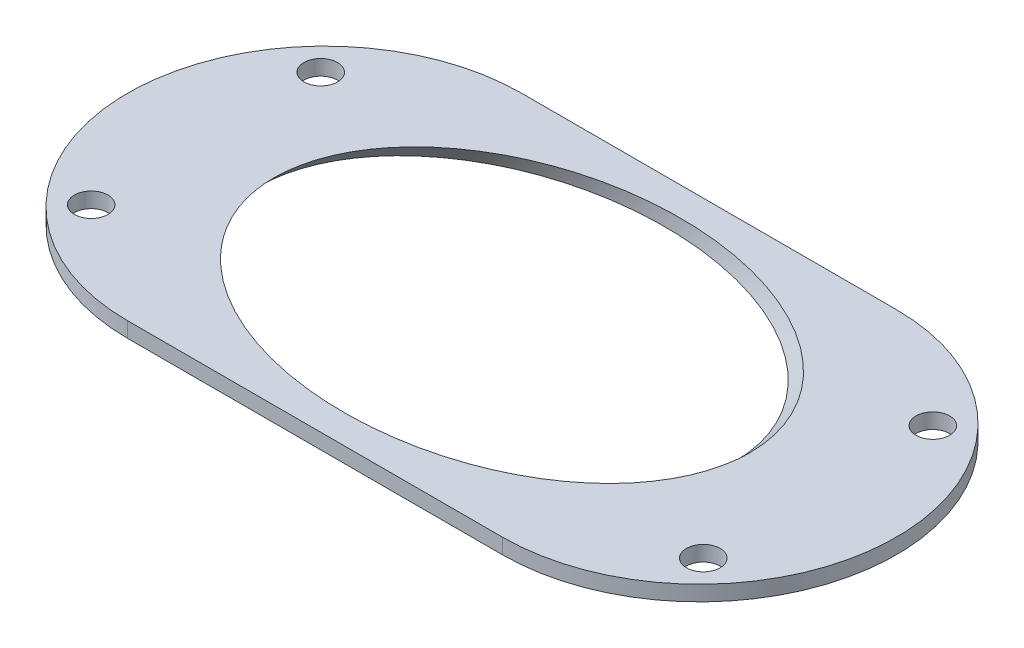
from build123d import *

# Parameters (mm, degrees)
BOSS_EXTRUDE1_DEPTH      = 1
SKETCH2_R                = 11
CUT_EXTRUDE1_DEPTH       = 10.811106589
CUT_EXTRUDE1_DEPTH_BACK  = 27.428115947
M2_CLEARANCE_HOLE1_D     = 2.2
M2_CLEARANCE_HOLE1_DEPTH = 1


with BuildPart() as part:
    # Sketch1 → Boss-Extrude1 (new body)
    with BuildSketch(Plane(origin=(0, 0, 0), x_dir=(1, 0, 0), z_dir=(0, 1, 0))):
        with BuildLine():
            Line((-12.25, 12.875), (12.25, 12.875))
            ThreePointArc((12.25, 12.875), (25.125, 0), (12.25, -12.875))
            Line((12.25, -12.875), (-12.25, -12.875))
            ThreePointArc((-12.25, -12.875), (-25.125, 0), (-12.25, 12.875))
        make_face()
    extrude(amount=BOSS_EXTRUDE1_DEPTH)

    # Sketch2 → Cut-Extrude1 (cut, two sides)
    with BuildSketch(Plane(origin=(6.125, 6.125, 0), x_dir=(0, 0, 1), z_dir=(0.707106781, 0.707106781, 0))) as cut_extrude1_sk:
        with Locations((0, -0.707106781)):
            Circle(SKETCH2_R)
    extrude(amount=CUT_EXTRUDE1_DEPTH, mode=Mode.SUBTRACT)
    extrude(cut_extrude1_sk.sketch, amount=-CUT_EXTRUDE1_DEPTH_BACK, mode=Mode.SUBTRACT)

    # M2 Clearance Hole1
    with Locations(Plane(origin=(0, 1, 0), x_dir=(1, 0, 0), z_dir=(0, 1, 0))):
        with Locations((-20, 7.5), (-20, -7.5), (20, -7.5), (20, 7.5)):
            Hole(M2_CLEARANCE_HOLE1_D / 2, depth=M2_CLEARANCE_HOLE1_DEPTH)


solid = part.part
